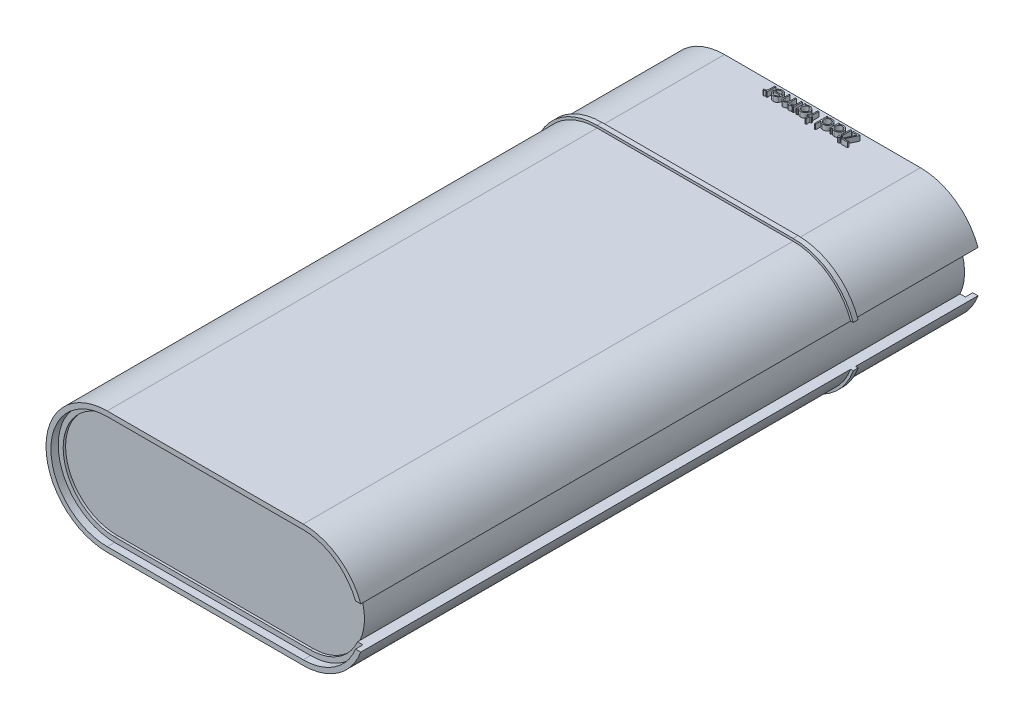
from build123d import *

# Parameters (mm, degrees)
BOSS_EXTRUDE2_DEPTH = 50
CUT_EXTRUDE8_DEPTH  = 3
BOSS_EXTRUDE3_DEPTH = 2
BOSS_EXTRUDE4_DEPTH = 200
CUT_EXTRUDE9_DEPTH  = 3
CUT_EXTRUDE14_DEPTH = 200
CUT_EXTRUDE15_DEPTH = 200
SKETCH31_W          = 19.676138418
SKETCH31_H          = 17.05397693
CUT_EXTRUDE16_DEPTH = 500
BOSS_EXTRUDE5_DEPTH = 245
SKETCH35_W          = 0.448717949
SKETCH35_H          = 3.653846154
BOSS_EXTRUDE7_DEPTH = 2


with BuildPart() as part:
    # Sketch6 → Boss-Extrude2 (new body)
    with BuildSketch(Plane.XY):
        with BuildLine():
            Line((-40, 25), (40, 25))
            ThreePointArc((40, 25), (65, 0), (40, -25))
            Line((40, -25), (-40, -25))
            ThreePointArc((-40, -25), (-65, 0), (-40, 25))
        make_face()
    extrude(amount=BOSS_EXTRUDE2_DEPTH)

    # Sketch12 → Cut-Extrude8 (cut)
    with BuildSketch(Plane(origin=(0, 0, 0), x_dir=(-1, 0, 0), z_dir=(0, 0, -1))):
        with BuildLine():
            Line((40, 23), (-40, 23))
            ThreePointArc((-40, 23), (-63, 0), (-40, -23))
            Line((-40, -23), (40, -23))
            ThreePointArc((40, -23), (63, 0), (40, 23))
        make_face()
    extrude(amount=-CUT_EXTRUDE8_DEPTH, mode=Mode.SUBTRACT)

    # Sketch13 → Boss-Extrude3 (add)
    with BuildSketch(Plane.XY.offset(50)):
        with BuildLine():
            Line((-40, -26), (40, -26))
            ThreePointArc((40, -26), (66, 0), (40, 26))
            Line((40, 26), (-40, 26))
            ThreePointArc((-40, 26), (-66, 0), (-40, -26))
        make_face()
    extrude(amount=BOSS_EXTRUDE3_DEPTH)

    # Sketch14 → Boss-Extrude4 (add)
    with BuildSketch(Plane.XY.offset(52)):
        with BuildLine():
            Line((-40, -25), (40, -25))
            ThreePointArc((40, -25), (65, 0), (40, 25))
            Line((40, 25), (-40, 25))
            ThreePointArc((-40, 25), (-65, 0), (-40, -25))
        make_face()
    extrude(amount=BOSS_EXTRUDE4_DEPTH)

    # Sketch16 → Cut-Extrude9 (cut)
    with BuildSketch(Plane.XY.offset(252)):
        with BuildLine():
            Line((-40, -23), (40, -23))
            ThreePointArc((40, -23), (63, 0), (40, 23))
            Line((40, 23), (-40, 23))
            ThreePointArc((-40, 23), (-63, 0), (-40, -23))
        make_face()
    extrude(amount=-CUT_EXTRUDE9_DEPTH, mode=Mode.SUBTRACT)

    # Sketch26 → Cut-Extrude14 (cut)
    with BuildSketch(Plane.XY.offset(249)):
        with BuildLine():
            Line((-40, -21), (40, -21))
            ThreePointArc((40, -21), (61, 0), (40, 21))
            Line((40, 21), (-40, 21))
            ThreePointArc((-40, 21), (-61, 0), (-40, -21))
        make_face()
    extrude(amount=-CUT_EXTRUDE14_DEPTH, mode=Mode.SUBTRACT)

    # Sketch27 → Cut-Extrude15 (cut)
    with BuildSketch(Plane(origin=(0, 0, 3), x_dir=(-1, 0, 0), z_dir=(0, 0, -1))):
        with BuildLine():
            Line((40, 21), (-40, 21))
            ThreePointArc((-40, 21), (-61, 0), (-40, -21))
            Line((-40, -21), (40, -21))
            ThreePointArc((40, -21), (61, 0), (40, 21))
        make_face()
    extrude(amount=-CUT_EXTRUDE15_DEPTH, mode=Mode.SUBTRACT)

    # Sketch31 → Cut-Extrude16 (cut)
    with BuildSketch(Plane(origin=(0, 0, -10), x_dir=(-1, 0, 0), z_dir=(0, 0, -1))):
        with Locations((-61, 0)):
            Rectangle(SKETCH31_W, SKETCH31_H)
    extrude(amount=-CUT_EXTRUDE16_DEPTH, mode=Mode.SUBTRACT)

    # Sketch34 → Boss-Extrude5 (add)
    with BuildSketch(Plane(origin=(0, 0, 3), x_dir=(-1, 0, 0), z_dir=(0, 0, -1))):
        with BuildLine():
            Line((40, 21), (-40, 21))
            ThreePointArc((-40, 21), (-61, 0), (-40, -21))
            Line((-40, -21), (40, -21))
            ThreePointArc((40, -21), (61, 0), (40, 21))
        make_face()
    extrude(amount=-BOSS_EXTRUDE5_DEPTH)

    # Sketch35 → Boss-Extrude7 (add)
    with BuildSketch(Plane(origin=(0, 25, 0), x_dir=(1, 0, 0), z_dir=(0, 1, 0))):
        with BuildLine():
            Line((-16.131712166, -6.523657446), (-16.580430115, -6.523657446))
            Line((-16.580430115, -6.523657446), (-16.580430115, -5.985796869))
            add(Edge.make_bspline(
                [(-16.580430115, -5.985796869), (-16.613531745, -6.035904276), (-16.676838356, -6.131734302), (-16.782618277, -6.258224339), (-16.889780261, -6.364620578), (-17.00196986, -6.447375657), (-17.116334059, -6.510437864), (-17.232534536, -6.555130606), (-17.351409876, -6.582372341), (-17.431653775, -6.585961714), (-17.471856397, -6.58776001)],
                knots=[0, 0, 0, 0, 1.280240866, 2.448450709, 3.511242029, 4.49418232, 5.41222037, 6.289222348, 7.142891256, 8, 8, 8, 8], degree=3))
            add(Edge.make_bspline(
                [(-17.471856397, -6.58776001), (-17.503046966, -6.586097305), (-17.566898729, -6.582693501), (-17.663850322, -6.557581502), (-17.764152055, -6.519010114), (-17.828878766, -6.481850806), (-17.862481397, -6.462559689)],
                knots=[0, 0, 0, 0, 0.90119973, 1.844890732, 2.881183062, 4, 4, 4, 4], degree=3))
            Line((-17.862481397, -6.462559689), (-17.616087166, -6.073937894))
            add(Edge.make_bspline(
                [(-17.616087166, -6.073937894), (-17.59450285, -6.083566846), (-17.553531687, -6.101844439), (-17.493596592, -6.123475882), (-17.43833754, -6.136212905), (-17.403132456, -6.138142501), (-17.386720179, -6.139042061)],
                knots=[0, 0, 0, 0, 1.180555205, 2.24091978, 3.179933427, 4, 4, 4, 4], degree=3))
            add(Edge.make_bspline(
                [(-17.386720179, -6.139042061), (-17.350339336, -6.136749253), (-17.276795767, -6.132114362), (-17.169338235, -6.092513978), (-17.063670258, -6.032997118), (-16.981605836, -5.962792103), (-16.917355013, -5.896639837), (-16.871118065, -5.838426196), (-16.829592111, -5.772591077), (-16.789319248, -5.701628182), (-16.751900368, -5.623771364), (-16.718461763, -5.538889344), (-16.687190032, -5.447684282), (-16.669579266, -5.384267225), (-16.66055832, -5.351782446)],
                knots=[0, 0, 0, 0, 1.1355652, 2.295535532, 3.545064593, 4.917862323, 5.656949634, 6.430545574, 7.239270929, 8.090880714, 8.983622437, 9.940313733, 10.94494545, 12, 12, 12, 12], degree=3))
            add(Edge.make_bspline(
                [(-16.66055832, -5.351782446), (-16.653786074, -5.322816658), (-16.638710844, -5.258337911), (-16.624444569, -5.150655912), (-16.609781163, -5.023515016), (-16.599767534, -4.876767524), (-16.590308326, -4.709849336), (-16.585082669, -4.523480537), (-16.580596377, -4.317148889), (-16.580487304, -4.173233375), (-16.580430115, -4.097776035)],
                knots=[0, 0, 0, 0, 0.566841273, 1.261806378, 2.068780918, 3.007109044, 4.065315289, 5.256255371, 6.561408263, 8, 8, 8, 8], degree=3))
            Line((-16.580430115, -4.097776035), (-16.580430115, -2.869811292))
            Line((-16.580430115, -2.869811292), (-16.131712166, -2.869811292))
            Line((-16.131712166, -2.869811292), (-16.131712166, -6.523657446))
        make_face()
        with BuildLine():
            Line((-14.771535884, -4.023657446), (-15.170173705, -3.81432251))
            add(Edge.make_bspline(
                [(-15.170173705, -3.81432251), (-15.138385898, -3.757992866), (-15.076539413, -3.648397686), (-14.970692477, -3.497742827), (-14.858583626, -3.363482847), (-14.737984937, -3.246248032), (-14.610409285, -3.143284341), (-14.473956808, -3.055059637), (-14.330897991, -2.978459842), (-14.179157806, -2.91602683), (-14.018881035, -2.866885241), (-13.849080279, -2.83060964), (-13.668969788, -2.80956948), (-13.545629733, -2.807016158), (-13.482473384, -2.805708728)],
                knots=[0, 0, 0, 0, 1.120547187, 2.180141081, 3.186367408, 4.148075574, 5.090720713, 6.023293347, 6.960451315, 7.899733127, 8.862572377, 9.862522039, 10.90550313, 12, 12, 12, 12], degree=3))
            add(Edge.make_bspline(
                [(-13.482473384, -2.805708728), (-13.41227056, -2.80734755), (-13.275325187, -2.810544417), (-13.075982685, -2.838105078), (-12.888297823, -2.883065599), (-12.712281027, -2.945873484), (-12.5483638, -3.027912631), (-12.396218695, -3.127854332), (-12.255051834, -3.245187699), (-12.129288191, -3.380919496), (-12.016137455, -3.52620162), (-11.916045313, -3.677486983), (-11.833334317, -3.834711794), (-11.762737209, -3.995488967), (-11.710501616, -4.161958294), (-11.671502896, -4.332653097), (-11.649651715, -4.50819846), (-11.646247963, -4.626899986), (-11.644532679, -4.686718343)],
                knots=[0, 0, 0, 0, 1.145213001, 2.233978795, 3.276616913, 4.289988888, 5.2768102, 6.260573508, 7.254647871, 8.264498533, 9.273731702, 10.25749501, 11.220258744, 12.169609138, 13.119022067, 14.062790212, 15.023763961, 16, 16, 16, 16], degree=3))
            add(Edge.make_bspline(
                [(-11.644532679, -4.686718343), (-11.646045738, -4.742853815), (-11.649044421, -4.854106907), (-11.667945546, -5.018771971), (-11.701443108, -5.178812618), (-11.747409285, -5.334361829), (-11.806768208, -5.485159163), (-11.879385664, -5.631296397), (-11.965374775, -5.772618025), (-12.031764309, -5.861765359), (-12.065205756, -5.906670266)],
                knots=[0, 0, 0, 0, 1.024358464, 2.0301432, 3.019427413, 4.004406732, 4.986367066, 5.972626655, 6.978780325, 8, 8, 8, 8], degree=3))
            add(Edge.make_bspline(
                [(-12.065205756, -5.906670266), (-12.110424355, -5.96085835), (-12.199283893, -6.067343917), (-12.351136408, -6.205986522), (-12.51335038, -6.324583419), (-12.687557486, -6.421335002), (-12.873464284, -6.495752267), (-13.070111882, -6.548684283), (-13.278043808, -6.581621001), (-13.420583418, -6.585682562), (-13.493491013, -6.58776001)],
                knots=[0, 0, 0, 0, 1.030811313, 2.025658015, 2.997072178, 3.962767568, 4.930766827, 5.917075773, 6.934604948, 8, 8, 8, 8], degree=3))
            add(Edge.make_bspline(
                [(-13.493491013, -6.58776001), (-13.568420471, -6.585835342), (-13.715414989, -6.582059583), (-13.929685719, -6.546742224), (-14.132831299, -6.491415458), (-14.323175273, -6.410806988), (-14.503650561, -6.310887282), (-14.670103544, -6.184593454), (-14.827103465, -6.038412101), (-14.918391871, -5.925875235), (-14.964845179, -5.868609369)],
                knots=[0, 0, 0, 0, 1.056389096, 2.072394598, 3.055233004, 4.020130009, 4.981825462, 5.957811105, 6.960805292, 8, 8, 8, 8], degree=3))
            add(Edge.make_bspline(
                [(-14.964845179, -5.868609369), (-14.996455091, -5.825461395), (-15.05946451, -5.739452654), (-15.138388938, -5.599208144), (-15.206899503, -5.452478724), (-15.261660876, -5.296892585), (-15.30600302, -5.134293185), (-15.33808419, -4.963518121), (-15.356897931, -4.784618247), (-15.36059607, -4.662723168), (-15.362481397, -4.600580522)],
                knots=[0, 0, 0, 0, 0.94817472, 1.890038105, 2.849395472, 3.817997239, 4.812318967, 5.836947057, 6.897266129, 8, 8, 8, 8], degree=3))
            Line((-15.362481397, -4.600580522), (-12.093250628, -4.600580522))
            add(Edge.make_bspline(
                [(-12.093250628, -4.600580522), (-12.095452154, -4.552437976), (-12.099781367, -4.4577676), (-12.11991617, -4.319224069), (-12.15180771, -4.187312305), (-12.196137876, -4.062594351), (-12.251723331, -3.944660716), (-12.317673893, -3.832698615), (-12.396835479, -3.728408406), (-12.484984899, -3.630438619), (-12.583151331, -3.543225129), (-12.68638934, -3.465104498), (-12.796053947, -3.399990729), (-12.911039635, -3.346341993), (-13.03194273, -3.305050331), (-13.158593209, -3.27661549), (-13.290597087, -3.257619585), (-13.3805758, -3.25550381), (-13.426383641, -3.254426676)],
                knots=[0, 0, 0, 0, 1.094405546, 2.152104367, 3.174987145, 4.173015398, 5.153654967, 6.133208507, 7.119289451, 8.123438607, 9.122504012, 10.097966803, 11.060604936, 12.014205423, 12.976096155, 13.956823727, 14.959826266, 16, 16, 16, 16], degree=3))
            add(Edge.make_bspline(
                [(-13.426383641, -3.254426676), (-13.471174091, -3.255282287), (-13.560046937, -3.256979983), (-13.692670231, -3.273973589), (-13.823450329, -3.300459832), (-13.950691411, -3.338891211), (-14.072355756, -3.38434198), (-14.185973215, -3.437484603), (-14.290476902, -3.497382954), (-14.387963149, -3.566511474), (-14.482006376, -3.6504708), (-14.575595811, -3.755441632), (-14.675048272, -3.880330251), (-14.73816304, -3.974083868), (-14.771535884, -4.023657446)],
                knots=[0, 0, 0, 0, 0.991026944, 1.966387566, 2.954903586, 3.941705208, 4.905318989, 5.827751054, 6.715113263, 7.568237245, 8.468614997, 9.499196909, 10.677664282, 12, 12, 12, 12], degree=3))
        make_face()
        with BuildLine():
            add(Edge.make_bspline(
                [(-14.913763448, -5.049298471), (-14.897434118, -5.108860819), (-14.866087107, -5.223201176), (-14.798906468, -5.381109243), (-14.726755621, -5.523063242), (-14.638152392, -5.645473621), (-14.53788062, -5.75361099), (-14.421701712, -5.847541701), (-14.293453858, -5.93370044), (-14.15080552, -6.005524509), (-13.999269978, -6.064525851), (-13.841993417, -6.107915309), (-13.680284558, -6.133419744), (-13.571370027, -6.137159146), (-13.516527872, -6.139042061)],
                knots=[0, 0, 0, 0, 1.154958961, 2.217145986, 3.207012531, 4.129872728, 5.036522214, 5.960144231, 6.920619777, 7.92424629, 8.943461387, 9.961007416, 10.973298156, 12, 12, 12, 12], degree=3))
            add(Edge.make_bspline(
                [(-13.516527872, -6.139042061), (-13.471740805, -6.138174697), (-13.38320619, -6.136460102), (-13.252807222, -6.11998097), (-13.127026643, -6.093149651), (-13.006467441, -6.054759942), (-12.890857296, -6.006487208), (-12.779665775, -5.94839134), (-12.674231231, -5.87770376), (-12.60831972, -5.823750817), (-12.575021461, -5.796493984)],
                knots=[0, 0, 0, 0, 1.04879286, 2.073242986, 3.073461291, 4.057960153, 5.032623303, 6.005244481, 6.992256684, 8, 8, 8, 8], degree=3))
            add(Edge.make_bspline(
                [(-12.575021461, -5.796493984), (-12.551170178, -5.774932942), (-12.502900994, -5.731298649), (-12.438472869, -5.656078694), (-12.376325169, -5.574920767), (-12.321097882, -5.484282249), (-12.268612544, -5.386791559), (-12.220784793, -5.281737331), (-12.177297588, -5.16867613), (-12.152885584, -5.089852255), (-12.140325948, -5.049298471)],
                knots=[0, 0, 0, 0, 0.879905587, 1.780714457, 2.708106151, 3.677566983, 4.684151534, 5.740052498, 6.837288539, 8, 8, 8, 8], degree=3))
            Line((-12.140325948, -5.049298471), (-14.913763448, -5.049298471))
        make_face(mode=Mode.SUBTRACT)
        with BuildLine():
            Line((-5.298378833, -6.523657446), (-5.747096782, -6.523657446))
            Line((-5.747096782, -6.523657446), (-5.747096782, -5.88864142))
            add(Edge.make_bspline(
                [(-5.747096782, -5.88864142), (-5.787590068, -5.944112944), (-5.865047624, -6.050221611), (-5.990844753, -6.191605009), (-6.11867841, -6.309617809), (-6.210090816, -6.372379748), (-6.253907679, -6.402463535)],
                knots=[0, 0, 0, 0, 1.134266299, 2.169680534, 3.122669868, 4, 4, 4, 4], degree=3))
            add(Edge.make_bspline(
                [(-6.253907679, -6.402463535), (-6.313714339, -6.431042629), (-6.432282768, -6.487701505), (-6.620024518, -6.545178018), (-6.812131188, -6.580499591), (-6.941857208, -6.585330124), (-7.007112807, -6.58776001)],
                knots=[0, 0, 0, 0, 1.014936303, 2.012140481, 3.000054389, 4, 4, 4, 4], degree=3))
            add(Edge.make_bspline(
                [(-7.007112807, -6.58776001), (-7.051244029, -6.586262751), (-7.138577343, -6.583299757), (-7.268006992, -6.564129325), (-7.393731486, -6.530591281), (-7.51494305, -6.485067568), (-7.628428882, -6.428151385), (-7.732744348, -6.362785655), (-7.826062134, -6.288810538), (-7.909773615, -6.204576723), (-7.98437905, -6.105328001), (-8.052526734, -5.98918294), (-8.116331438, -5.854461083), (-8.151472436, -5.756776758), (-8.169973384, -5.705348151)],
                knots=[0, 0, 0, 0, 1.009705358, 1.998152609, 2.985684482, 3.981629544, 4.955207608, 5.885544107, 6.793375404, 7.673799057, 8.595028447, 9.626006337, 10.750145549, 12, 12, 12, 12], degree=3))
            add(Edge.make_bspline(
                [(-8.169973384, -5.705348151), (-8.189561245, -5.740668365), (-8.228107403, -5.810173586), (-8.292824622, -5.908548031), (-8.36065446, -6.000537648), (-8.432065254, -6.086333133), (-8.507357087, -6.165251031), (-8.585316202, -6.238903185), (-8.6676908, -6.305243048), (-8.781621575, -6.382891599), (-8.92948704, -6.465312421), (-9.116702663, -6.535886445), (-9.311098443, -6.579897419), (-9.443449071, -6.585126156), (-9.510117615, -6.58776001)],
                knots=[0, 0, 0, 0, 0.861004964, 1.694336854, 2.508842991, 3.297356609, 4.072906766, 4.833509053, 5.582933055, 6.32546011, 7.772130661, 9.180397307, 10.579690848, 12, 12, 12, 12], degree=3))
            add(Edge.make_bspline(
                [(-9.510117615, -6.58776001), (-9.571387493, -6.585478636), (-9.691298592, -6.581013767), (-9.865573575, -6.545124254), (-10.028798591, -6.485723826), (-10.179243621, -6.402188326), (-10.315160482, -6.297713283), (-10.433753382, -6.173261047), (-10.532414809, -6.029286156), (-10.598372671, -5.894925309), (-10.64228178, -5.776081852), (-10.669704799, -5.674361599), (-10.693463116, -5.562315274), (-10.713606585, -5.440032999), (-10.728169391, -5.307267189), (-10.73899521, -5.163956843), (-10.746312236, -5.009977428), (-10.746829923, -4.903741097), (-10.747096782, -4.848977958)],
                knots=[0, 0, 0, 0, 1.209392158, 2.366897878, 3.497663982, 4.628180075, 5.751982922, 6.871462727, 8.009245026, 9.185977379, 9.818124946, 10.509294143, 11.264649411, 12.079922034, 12.956003306, 13.901808055, 14.918415426, 16, 16, 16, 16], degree=3))
            Line((-10.747096782, -4.848977958), (-10.747096782, -2.869811292))
            Line((-10.747096782, -2.869811292), (-10.298378833, -2.869811292))
            Line((-10.298378833, -2.869811292), (-10.298378833, -4.850981164))
            add(Edge.make_bspline(
                [(-10.298378833, -4.850981164), (-10.298268112, -4.897724909), (-10.298055322, -4.98755928), (-10.294200176, -5.116490448), (-10.286973178, -5.234019661), (-10.278393018, -5.340300331), (-10.266795099, -5.435299082), (-10.251482261, -5.518749957), (-10.235388555, -5.591033478), (-10.208588622, -5.671134412), (-10.166140502, -5.75941821), (-10.100314968, -5.853951332), (-10.018588909, -5.936817658), (-9.923599475, -6.009189992), (-9.815267653, -6.066889273), (-9.696349984, -6.109643112), (-9.56727401, -6.13491983), (-9.477845409, -6.137644856), (-9.431992615, -6.139042061)],
                knots=[0, 0, 0, 0, 1.25342297, 2.408888324, 3.45823814, 4.41064868, 5.267922422, 6.023041539, 6.685366708, 7.251591043, 8.284698338, 9.300514895, 10.326147092, 11.393333517, 12.490845139, 13.603767677, 14.771377999, 16, 16, 16, 16], degree=3))
            add(Edge.make_bspline(
                [(-9.431992615, -6.139042061), (-9.375379078, -6.136411156), (-9.263263459, -6.131200998), (-9.098915691, -6.093327321), (-8.943082763, -6.028790384), (-8.796343063, -5.94179913), (-8.662433921, -5.834483932), (-8.546788484, -5.707559416), (-8.451333765, -5.563762657), (-8.386681725, -5.430705676), (-8.345837042, -5.311176922), (-8.31888312, -5.206750641), (-8.297790216, -5.087745086), (-8.278391108, -4.955555732), (-8.265299018, -4.809056966), (-8.253733593, -4.649153379), (-8.248251482, -4.474750341), (-8.247491412, -4.353854692), (-8.247096782, -4.29108533)],
                knots=[0, 0, 0, 0, 1.091115267, 2.160809405, 3.231897231, 4.331486719, 5.439373414, 6.528416898, 7.628213638, 8.756851852, 9.369612525, 10.061283877, 10.83397277, 11.69882403, 12.636571156, 13.668968181, 14.789721711, 16, 16, 16, 16], degree=3))
            Line((-8.247096782, -4.29108533), (-8.247096782, -2.869811292))
            Line((-8.247096782, -2.869811292), (-7.798378833, -2.869811292))
            Line((-7.798378833, -2.869811292), (-7.798378833, -4.727784048))
            add(Edge.make_bspline(
                [(-7.798378833, -4.727784048), (-7.798270444, -4.780203668), (-7.798061916, -4.881053748), (-7.794171659, -5.025665473), (-7.787124982, -5.157235533), (-7.778023652, -5.27543361), (-7.768145516, -5.380580777), (-7.752513383, -5.472332509), (-7.736217668, -5.551069397), (-7.711352002, -5.638263736), (-7.668264322, -5.732828427), (-7.602803583, -5.834496767), (-7.521053858, -5.923934856), (-7.424989524, -6.000948263), (-7.315638062, -6.063353429), (-7.195101443, -6.107401644), (-7.065031155, -6.134032752), (-6.975190786, -6.137340802), (-6.928987807, -6.139042061)],
                knots=[0, 0, 0, 0, 1.320037001, 2.539618509, 3.642599628, 4.637590735, 5.525231343, 6.300657295, 6.980070891, 7.549441006, 8.580679949, 9.583455601, 10.583372174, 11.61806701, 12.672388285, 13.739107491, 14.837271374, 16, 16, 16, 16], degree=3))
            add(Edge.make_bspline(
                [(-6.928987807, -6.139042061), (-6.874678948, -6.136855682), (-6.76644332, -6.132498308), (-6.607440296, -6.093278022), (-6.453890136, -6.031843217), (-6.308237398, -5.946616504), (-6.174429176, -5.841040338), (-6.057230085, -5.716898631), (-5.95907971, -5.575847142), (-5.893290876, -5.444755229), (-5.85115549, -5.328180673), (-5.823393185, -5.228697294), (-5.799612755, -5.118293549), (-5.779676377, -4.997321638), (-5.76462915, -4.86528197), (-5.755638124, -4.722527865), (-5.74773032, -4.56861442), (-5.747313141, -4.462371493), (-5.747096782, -4.407271228)],
                knots=[0, 0, 0, 0, 1.098782694, 2.18983489, 3.297678452, 4.440407233, 5.596094952, 6.739704233, 7.886210376, 9.065955464, 9.69932744, 10.395238925, 11.156791145, 11.986349475, 12.878233552, 13.847858808, 14.883845232, 16, 16, 16, 16], degree=3))
            Line((-5.747096782, -4.407271228), (-5.747096782, -2.869811292))
            Line((-5.747096782, -2.869811292), (-5.298378833, -2.869811292))
            Line((-5.298378833, -2.869811292), (-5.298378833, -6.523657446))
        make_face()
        with BuildLine():
            Line((-4.272737807, -6.523657446), (-4.272737807, -2.869811292))
            Line((-4.272737807, -2.869811292), (-3.824019859, -2.869811292))
            Line((-3.824019859, -2.869811292), (-3.824019859, -3.50182251))
            add(Edge.make_bspline(
                [(-3.824019859, -3.50182251), (-3.773353037, -3.444701956), (-3.674329057, -3.333064708), (-3.510524635, -3.186320205), (-3.335457578, -3.066510541), (-3.15211048, -2.969260802), (-2.959064173, -2.895952109), (-2.757452407, -2.844307043), (-2.54743293, -2.810711193), (-2.404211029, -2.807391176), (-2.331632038, -2.805708728)],
                knots=[0, 0, 0, 0, 1.074235403, 2.099501444, 3.086304576, 4.053325556, 5.01427503, 5.985443889, 6.979105517, 8, 8, 8, 8], degree=3))
            add(Edge.make_bspline(
                [(-2.331632038, -2.805708728), (-2.267106214, -2.807460397), (-2.139858433, -2.810914767), (-1.952676559, -2.837722239), (-1.772535464, -2.880750548), (-1.599320341, -2.940665776), (-1.434204864, -3.019731177), (-1.276258652, -3.115411233), (-1.125113086, -3.228234921), (-0.983642639, -3.357718686), (-0.853203381, -3.498207722), (-0.739082205, -3.64848835), (-0.642360793, -3.806496468), (-0.562873114, -3.972187669), (-0.501361381, -4.14544083), (-0.458565858, -4.326137098), (-0.431787275, -4.513975803), (-0.428334655, -4.641889953), (-0.426583961, -4.706750394)],
                knots=[0, 0, 0, 0, 1.034036272, 2.039165313, 3.024406509, 3.999331371, 4.971254918, 5.953351348, 6.95522652, 7.989525907, 9.023492927, 10.024309745, 11.009187477, 11.988246066, 12.964946762, 13.950187958, 14.960617622, 16, 16, 16, 16], degree=3))
            add(Edge.make_bspline(
                [(-0.426583961, -4.706750394), (-0.428373484, -4.770270242), (-0.431911275, -4.895845553), (-0.458279318, -5.080525495), (-0.50258607, -5.258423169), (-0.564883454, -5.428879576), (-0.644413401, -5.592581202), (-0.742798203, -5.748247241), (-0.856878256, -5.898258945), (-0.988711579, -6.037805706), (-1.131451776, -6.166238953), (-1.283442986, -6.279336825), (-1.442790032, -6.374771566), (-1.609812427, -6.452350732), (-1.783327504, -6.513999861), (-1.964653366, -6.556975239), (-2.152965415, -6.582237882), (-2.280807632, -6.585901614), (-2.345654474, -6.58776001)],
                knots=[0, 0, 0, 0, 1.02050356, 2.017480486, 2.990790918, 3.96161403, 4.928589988, 5.909588639, 6.91611943, 7.952353252, 8.989586576, 9.99823133, 10.991940466, 11.968822692, 12.952985106, 13.945868367, 14.958059758, 16, 16, 16, 16], degree=3))
            add(Edge.make_bspline(
                [(-2.345654474, -6.58776001), (-2.420227189, -6.585713791), (-2.566460764, -6.581701252), (-2.780655634, -6.548023922), (-2.983379734, -6.491655237), (-3.176388969, -6.414717791), (-3.356970936, -6.31111043), (-3.526861643, -6.18291334), (-3.684045275, -6.027018603), (-3.77655454, -5.908424718), (-3.824019859, -5.847575715)],
                knots=[0, 0, 0, 0, 1.038908319, 2.037250181, 3.012632028, 3.966567879, 4.9252131, 5.905168122, 6.925168603, 8, 8, 8, 8], degree=3))
            Line((-3.824019859, -5.847575715), (-3.824019859, -6.523657446))
            Line((-3.824019859, -6.523657446), (-4.272737807, -6.523657446))
        make_face()
        with BuildLine():
            add(Edge.make_bspline(
                [(-2.351664089, -6.139042061), (-2.28607355, -6.136706321), (-2.156608259, -6.132095941), (-1.966525556, -6.096162325), (-1.784723814, -6.036220019), (-1.611498677, -5.954714402), (-1.451632577, -5.850308221), (-1.306386792, -5.727205239), (-1.179698684, -5.583897207), (-1.072580325, -5.423676652), (-0.983652235, -5.252942186), (-0.922284945, -5.073163966), (-0.881524514, -4.889201034), (-0.877381512, -4.764391298), (-0.87530191, -4.701742381)],
                knots=[0, 0, 0, 0, 1.031179624, 2.035384561, 3.030098214, 4.035455833, 5.037557836, 6.024646278, 7.02156144, 8.035264006, 9.049836703, 10.039645228, 11.015989397, 12, 12, 12, 12], degree=3))
            add(Edge.make_bspline(
                [(-0.87530191, -4.701742381), (-0.87800149, -4.639483173), (-0.883390069, -4.51520879), (-0.921032725, -4.330963942), (-0.987106498, -4.152358634), (-1.074089325, -3.97942332), (-1.182893865, -3.818007693), (-1.309331926, -3.672053555), (-1.455314718, -3.547052944), (-1.616588537, -3.442351666), (-1.788654818, -3.3581279), (-1.969667253, -3.298724611), (-2.156470853, -3.261217895), (-2.283714369, -3.256698031), (-2.347657679, -3.254426676)],
                knots=[0, 0, 0, 0, 0.979235476, 1.954632679, 2.943119654, 3.967171814, 4.992637064, 5.997548408, 6.995574264, 8.005058949, 9.015076297, 9.999929117, 10.994910263, 12, 12, 12, 12], degree=3))
            add(Edge.make_bspline(
                [(-2.347657679, -3.254426676), (-2.412580221, -3.256789783), (-2.541376317, -3.261477814), (-2.732116272, -3.297659246), (-2.91687682, -3.358345849), (-3.094153296, -3.440983078), (-3.259020778, -3.543433142), (-3.406303276, -3.663905253), (-3.533541188, -3.801868339), (-3.638300639, -3.956498032), (-3.722002025, -4.124148599), (-3.781268956, -4.303215682), (-3.817265603, -4.492635201), (-3.82173731, -4.62245567), (-3.824019859, -4.688721548)],
                knots=[0, 0, 0, 0, 1.017730373, 2.019016736, 3.032373701, 4.060729657, 5.079187105, 6.068726676, 7.03591854, 8.011858086, 8.988317194, 9.965225429, 10.961364673, 12, 12, 12, 12], degree=3))
            add(Edge.make_bspline(
                [(-3.824019859, -4.688721548), (-3.822648899, -4.739204144), (-3.819950418, -4.838569867), (-3.799335628, -4.984466599), (-3.766541742, -5.124085189), (-3.720337053, -5.257578453), (-3.659619881, -5.384186114), (-3.586466588, -5.504900599), (-3.499376691, -5.618597469), (-3.401000557, -5.725132738), (-3.2921048, -5.821817515), (-3.176308275, -5.907034666), (-3.053902325, -5.979151825), (-2.924972873, -6.036864415), (-2.790512942, -6.083881416), (-2.64923376, -6.114935332), (-2.502559161, -6.136326687), (-2.402492036, -6.138127406), (-2.351664089, -6.139042061)],
                knots=[0, 0, 0, 0, 1.050062701, 2.066855696, 3.059271411, 4.030305351, 4.999747758, 5.975466543, 6.961907836, 7.974539719, 8.98812422, 9.98710676, 10.961662635, 11.93785114, 12.922015094, 13.919620009, 14.94329489, 16, 16, 16, 16], degree=3))
        make_face(mode=Mode.SUBTRACT)
        Polygon((1.368287834, -7.99801642), (0.919569885, -7.99801642), (0.919569885, -6.523657446), (0.278544244, -6.523657446), (0.278544244, -6.074939497), (0.919569885, -6.074939497), (0.919569885, -2.869811292), (1.368287834, -2.869811292), (1.368287834, -6.074939497), (2.009313475, -6.074939497), (2.009313475, -6.523657446), (1.368287834, -6.523657446), align=None)
        with BuildLine():
            Line((4.765723731, -7.99801642), (4.765723731, -2.869811292))
            Line((4.765723731, -2.869811292), (5.21444168, -2.869811292))
            Line((5.21444168, -2.869811292), (5.21444168, -3.50182251))
            add(Edge.make_bspline(
                [(5.21444168, -3.50182251), (5.265108501, -3.444701956), (5.364132482, -3.333064708), (5.527936903, -3.186320205), (5.70300396, -3.066510541), (5.886351058, -2.969260802), (6.079397365, -2.895952109), (6.281009131, -2.844307043), (6.491028609, -2.810711193), (6.63425051, -2.807391176), (6.7068295, -2.805708728)],
                knots=[0, 0, 0, 0, 1.074235403, 2.099501444, 3.086304576, 4.053325556, 5.01427503, 5.985443889, 6.979105517, 8, 8, 8, 8], degree=3))
            add(Edge.make_bspline(
                [(6.7068295, -2.805708728), (6.771355324, -2.807460397), (6.898603105, -2.810914767), (7.08578498, -2.837722239), (7.265926075, -2.880750548), (7.439141198, -2.940665776), (7.604256674, -3.019731177), (7.762202886, -3.115411233), (7.913348452, -3.228234921), (8.054818899, -3.357718686), (8.185258157, -3.498207722), (8.299379333, -3.64848835), (8.396100746, -3.806496468), (8.475588424, -3.972187669), (8.537100158, -4.14544083), (8.579895681, -4.326137098), (8.606674264, -4.513975803), (8.610126884, -4.641889953), (8.611877577, -4.706750394)],
                knots=[0, 0, 0, 0, 1.034036272, 2.039165313, 3.024406509, 3.999331371, 4.971254918, 5.953351348, 6.95522652, 7.989525907, 9.023492927, 10.024309745, 11.009187477, 11.988246066, 12.964946762, 13.950187958, 14.960617622, 16, 16, 16, 16], degree=3))
            add(Edge.make_bspline(
                [(8.611877577, -4.706750394), (8.610088054, -4.770270242), (8.606550263, -4.895845553), (8.58018222, -5.080525495), (8.535875469, -5.258423169), (8.473578085, -5.428879576), (8.394048137, -5.592581202), (8.295663335, -5.748247241), (8.181583283, -5.898258945), (8.049749959, -6.037805706), (7.907009763, -6.166238953), (7.755018553, -6.279336825), (7.595671507, -6.374771566), (7.428649112, -6.452350732), (7.255134034, -6.513999861), (7.073808172, -6.556975239), (6.885496123, -6.582237882), (6.757653907, -6.585901614), (6.692807064, -6.58776001)],
                knots=[0, 0, 0, 0, 1.02050356, 2.017480486, 2.990790918, 3.96161403, 4.928589988, 5.909588639, 6.91611943, 7.952353252, 8.989586576, 9.99823133, 10.991940466, 11.968822692, 12.952985106, 13.945868367, 14.958059758, 16, 16, 16, 16], degree=3))
            add(Edge.make_bspline(
                [(6.692807064, -6.58776001), (6.618200314, -6.585560289), (6.471755554, -6.581242481), (6.257554189, -6.543927175), (6.054204777, -6.484198137), (5.861715126, -6.399356059), (5.681774837, -6.288786591), (5.511978486, -6.155815029), (5.354927727, -5.997098432), (5.261984326, -5.877634521), (5.21444168, -5.816526035)],
                knots=[0, 0, 0, 0, 1.03083325, 2.023411113, 2.996083796, 3.9549903, 4.922369457, 5.908572979, 6.930187902, 8, 8, 8, 8], degree=3))
            Line((5.21444168, -5.816526035), (5.21444168, -7.99801642))
            Line((5.21444168, -7.99801642), (4.765723731, -7.99801642))
        make_face()
        with BuildLine():
            add(Edge.make_bspline(
                [(6.686797449, -6.139042061), (6.752387988, -6.136706321), (6.88185328, -6.132095941), (7.071935983, -6.096162325), (7.253737724, -6.036220019), (7.426962861, -5.954714402), (7.586828961, -5.850308221), (7.732074747, -5.727205239), (7.858762854, -5.583897207), (7.965881213, -5.423676652), (8.054809304, -5.252942186), (8.116176593, -5.073163966), (8.156937024, -4.889201034), (8.161080026, -4.764391298), (8.163159628, -4.701742381)],
                knots=[0, 0, 0, 0, 1.031179624, 2.035384561, 3.030098214, 4.035455833, 5.037557836, 6.024646278, 7.02156144, 8.035264006, 9.049836703, 10.039645228, 11.015989397, 12, 12, 12, 12], degree=3))
            add(Edge.make_bspline(
                [(8.163159628, -4.701742381), (8.160460049, -4.639483173), (8.15507147, -4.51520879), (8.117428813, -4.330963942), (8.05135504, -4.152358634), (7.964372214, -3.97942332), (7.855567674, -3.818007693), (7.729129612, -3.672053555), (7.58314682, -3.547052944), (7.421873002, -3.442351666), (7.249806721, -3.3581279), (7.068794286, -3.298724611), (6.881990686, -3.261217895), (6.754747169, -3.256698031), (6.690803859, -3.254426676)],
                knots=[0, 0, 0, 0, 0.979235476, 1.954632679, 2.943119654, 3.967171814, 4.992637064, 5.997548408, 6.995574264, 8.005058949, 9.015076297, 9.999929117, 10.994910263, 12, 12, 12, 12], degree=3))
            add(Edge.make_bspline(
                [(6.690803859, -3.254426676), (6.625881317, -3.256789783), (6.497085222, -3.261477814), (6.306345267, -3.297659246), (6.121584719, -3.358345849), (5.944308243, -3.440983078), (5.77944076, -3.543433142), (5.632158263, -3.663905253), (5.504920351, -3.801868339), (5.400160899, -3.956498032), (5.316459513, -4.124148599), (5.257192582, -4.303215682), (5.221195936, -4.492635201), (5.216724229, -4.62245567), (5.21444168, -4.688721548)],
                knots=[0, 0, 0, 0, 1.017730373, 2.019016736, 3.032373701, 4.060729657, 5.079187105, 6.068726676, 7.03591854, 8.011858086, 8.988317194, 9.965225429, 10.961364673, 12, 12, 12, 12], degree=3))
            add(Edge.make_bspline(
                [(5.21444168, -4.688721548), (5.215812639, -4.739204144), (5.218511121, -4.838569867), (5.239125911, -4.984466599), (5.271919796, -5.124085189), (5.318124486, -5.257578453), (5.378841657, -5.384186114), (5.45199495, -5.504900599), (5.539084847, -5.618597469), (5.637460981, -5.725132738), (5.746356739, -5.821817515), (5.862153264, -5.907034666), (5.984559213, -5.979151825), (6.113488666, -6.036864415), (6.247948596, -6.083881416), (6.389227779, -6.114935332), (6.535902377, -6.136326687), (6.635969503, -6.138127406), (6.686797449, -6.139042061)],
                knots=[0, 0, 0, 0, 1.050062701, 2.066855696, 3.059271411, 4.030305351, 4.999747758, 5.975466543, 6.961907836, 7.974539719, 8.98812422, 9.98710676, 10.961662635, 11.93785114, 12.922015094, 13.919620009, 14.94329489, 16, 16, 16, 16], degree=3))
        make_face(mode=Mode.SUBTRACT)
        with BuildLine():
            Line((9.509313475, -6.523657446), (9.509313475, -2.869811292))
            Line((9.509313475, -2.869811292), (9.958031423, -2.869811292))
            Line((9.958031423, -2.869811292), (9.958031423, -3.50182251))
            add(Edge.make_bspline(
                [(9.958031423, -3.50182251), (10.008698245, -3.444701956), (10.107722225, -3.333064708), (10.271526647, -3.186320205), (10.446593704, -3.066510541), (10.629940802, -2.969260802), (10.822987109, -2.895952109), (11.024598875, -2.844307043), (11.234618352, -2.810711193), (11.377840253, -2.807391176), (11.450419244, -2.805708728)],
                knots=[0, 0, 0, 0, 1.074235403, 2.099501444, 3.086304576, 4.053325556, 5.01427503, 5.985443889, 6.979105517, 8, 8, 8, 8], degree=3))
            add(Edge.make_bspline(
                [(11.450419244, -2.805708728), (11.514945068, -2.807460397), (11.642192849, -2.810914767), (11.829374723, -2.837722239), (12.009515818, -2.880750548), (12.182730941, -2.940665776), (12.347846418, -3.019731177), (12.50579263, -3.115411233), (12.656938196, -3.228234921), (12.798408643, -3.357718686), (12.928847901, -3.498207722), (13.042969077, -3.64848835), (13.13969049, -3.806496468), (13.219178168, -3.972187669), (13.280689901, -4.14544083), (13.323485424, -4.326137098), (13.350264007, -4.513975803), (13.353716627, -4.641889953), (13.355467321, -4.706750394)],
                knots=[0, 0, 0, 0, 1.034036272, 2.039165313, 3.024406509, 3.999331371, 4.971254918, 5.953351348, 6.95522652, 7.989525907, 9.023492927, 10.024309745, 11.009187477, 11.988246066, 12.964946762, 13.950187958, 14.960617622, 16, 16, 16, 16], degree=3))
            add(Edge.make_bspline(
                [(13.355467321, -4.706750394), (13.353677798, -4.770270242), (13.350140007, -4.895845553), (13.323771964, -5.080525495), (13.279465212, -5.258423169), (13.217167828, -5.428879576), (13.137637881, -5.592581202), (13.039253079, -5.748247241), (12.925173026, -5.898258945), (12.793339703, -6.037805706), (12.650599506, -6.166238953), (12.498608296, -6.279336825), (12.33926125, -6.374771566), (12.172238855, -6.452350732), (11.998723778, -6.513999861), (11.817397916, -6.556975239), (11.629085867, -6.582237882), (11.50124365, -6.585901614), (11.436396808, -6.58776001)],
                knots=[0, 0, 0, 0, 1.02050356, 2.017480486, 2.990790918, 3.96161403, 4.928589988, 5.909588639, 6.91611943, 7.952353252, 8.989586576, 9.99823133, 10.991940466, 11.968822692, 12.952985106, 13.945868367, 14.958059758, 16, 16, 16, 16], degree=3))
            add(Edge.make_bspline(
                [(11.436396808, -6.58776001), (11.361824093, -6.585713791), (11.215590518, -6.581701252), (11.001395648, -6.548023922), (10.798671548, -6.491655237), (10.605662313, -6.414717791), (10.425080346, -6.31111043), (10.255189639, -6.18291334), (10.098006007, -6.027018603), (10.005496742, -5.908424718), (9.958031423, -5.847575715)],
                knots=[0, 0, 0, 0, 1.038908319, 2.037250181, 3.012632028, 3.966567879, 4.9252131, 5.905168122, 6.925168603, 8, 8, 8, 8], degree=3))
            Line((9.958031423, -5.847575715), (9.958031423, -6.523657446))
            Line((9.958031423, -6.523657446), (9.509313475, -6.523657446))
        make_face()
        with BuildLine():
            add(Edge.make_bspline(
                [(11.430387193, -6.139042061), (11.495977732, -6.136706321), (11.625443023, -6.132095941), (11.815525726, -6.096162325), (11.997327468, -6.036220019), (12.170552605, -5.954714402), (12.330418705, -5.850308221), (12.475664491, -5.727205239), (12.602352598, -5.583897207), (12.709470957, -5.423676652), (12.798399047, -5.252942186), (12.859766337, -5.073163966), (12.900526768, -4.889201034), (12.90466977, -4.764391298), (12.906749372, -4.701742381)],
                knots=[0, 0, 0, 0, 1.031179624, 2.035384561, 3.030098214, 4.035455833, 5.037557836, 6.024646278, 7.02156144, 8.035264006, 9.049836703, 10.039645228, 11.015989397, 12, 12, 12, 12], degree=3))
            add(Edge.make_bspline(
                [(12.906749372, -4.701742381), (12.904049792, -4.639483173), (12.898661214, -4.51520879), (12.861018557, -4.330963942), (12.794944784, -4.152358634), (12.707961958, -3.97942332), (12.599157417, -3.818007693), (12.472719356, -3.672053555), (12.326736564, -3.547052944), (12.165462745, -3.442351666), (11.993396465, -3.3581279), (11.812384029, -3.298724611), (11.625580429, -3.261217895), (11.498336913, -3.256698031), (11.434393603, -3.254426676)],
                knots=[0, 0, 0, 0, 0.979235476, 1.954632679, 2.943119654, 3.967171814, 4.992637064, 5.997548408, 6.995574264, 8.005058949, 9.015076297, 9.999929117, 10.994910263, 12, 12, 12, 12], degree=3))
            add(Edge.make_bspline(
                [(11.434393603, -3.254426676), (11.369471061, -3.256789783), (11.240674965, -3.261477814), (11.04993501, -3.297659246), (10.865174462, -3.358345849), (10.687897986, -3.440983078), (10.523030504, -3.543433142), (10.375748006, -3.663905253), (10.248510094, -3.801868339), (10.143750643, -3.956498032), (10.060049257, -4.124148599), (10.000782326, -4.303215682), (9.96478568, -4.492635201), (9.960313972, -4.62245567), (9.958031423, -4.688721548)],
                knots=[0, 0, 0, 0, 1.017730373, 2.019016736, 3.032373701, 4.060729657, 5.079187105, 6.068726676, 7.03591854, 8.011858086, 8.988317194, 9.965225429, 10.961364673, 12, 12, 12, 12], degree=3))
            add(Edge.make_bspline(
                [(9.958031423, -4.688721548), (9.959402383, -4.739204144), (9.962100865, -4.838569867), (9.982715654, -4.984466599), (10.01550954, -5.124085189), (10.061714229, -5.257578453), (10.122431401, -5.384186114), (10.195584694, -5.504900599), (10.282674591, -5.618597469), (10.381050725, -5.725132738), (10.489946482, -5.821817515), (10.605743007, -5.907034666), (10.728148957, -5.979151825), (10.857078409, -6.036864415), (10.99153834, -6.083881416), (11.132817522, -6.114935332), (11.279492121, -6.136326687), (11.379559246, -6.138127406), (11.430387193, -6.139042061)],
                knots=[0, 0, 0, 0, 1.050062701, 2.066855696, 3.059271411, 4.030305351, 4.999747758, 5.975466543, 6.961907836, 7.974539719, 8.98812422, 9.98710676, 10.961662635, 11.93785114, 12.922015094, 13.919620009, 14.94329489, 16, 16, 16, 16], degree=3))
        make_face(mode=Mode.SUBTRACT)
        with BuildLine():
            add(Edge.make_bspline(
                [(14.479265398, -8.062118984), (14.45142531, -8.060821735), (14.396909071, -8.058281472), (14.317995509, -8.036701801), (14.246211514, -7.999564982), (14.18159067, -7.951360486), (14.12802296, -7.892338888), (14.089612061, -7.825277306), (14.065090661, -7.752270335), (14.062112071, -7.701400633), (14.060595526, -7.675500394)],
                knots=[0, 0, 0, 0, 1.054986045, 2.065865298, 3.074122704, 4.105114675, 5.109626121, 6.074217918, 7.019490725, 8, 8, 8, 8], degree=3))
            add(Edge.make_bspline(
                [(14.060595526, -7.675500394), (14.062145997, -7.650272446), (14.065211095, -7.600399777), (14.089593934, -7.528658653), (14.12834499, -7.46253089), (14.181555016, -7.403624683), (14.246220931, -7.355448035), (14.317993018, -7.318303858), (14.396909727, -7.296726132), (14.451425532, -7.294185601), (14.479265398, -7.292888215)],
                knots=[0, 0, 0, 0, 0.961106377, 1.899993565, 2.859409042, 3.870007927, 4.90724781, 5.921615355, 6.938620636, 8, 8, 8, 8], degree=3))
            add(Edge.make_bspline(
                [(14.479265398, -7.292888215), (14.506785517, -7.294143933), (14.560349833, -7.296588025), (14.637812406, -7.318562017), (14.708441371, -7.355367262), (14.772005423, -7.404291384), (14.826270413, -7.462139202), (14.864878489, -7.528708604), (14.88932652, -7.600387059), (14.892382832, -7.650268173), (14.893928859, -7.675500394)],
                knots=[0, 0, 0, 0, 1.055304112, 2.054011575, 3.063363921, 4.096942562, 5.122536081, 6.088009498, 7.032825006, 8, 8, 8, 8], degree=3))
            add(Edge.make_bspline(
                [(14.893928859, -7.675500394), (14.892416924, -7.701405067), (14.889447387, -7.752283478), (14.864859513, -7.825226501), (14.826596415, -7.892733917), (14.77197036, -7.950694269), (14.70845055, -7.999645578), (14.637810016, -8.036443713), (14.560350467, -8.058419564), (14.506785732, -8.060863398), (14.479265398, -8.062118984)],
                knots=[0, 0, 0, 0, 0.986662878, 1.937868148, 2.908513651, 3.927890639, 4.955204348, 5.958438607, 6.951092507, 8, 8, 8, 8], degree=3))
        make_face()
        with Locations((14.477262192, -4.696734369)):
            Rectangle(SKETCH35_W, SKETCH35_H)
        Polygon((18.099057064, -7.356990779), (18.099057064, -7.869811292), (15.470851936, -7.869811292), (17.567206103, -3.382631805), (15.5349545, -3.382631805), (15.5349545, -2.869811292), (18.291364757, -2.869811292), (16.196012193, -7.356990779), align=None)
    extrude(amount=BOSS_EXTRUDE7_DEPTH)


solid = part.part
